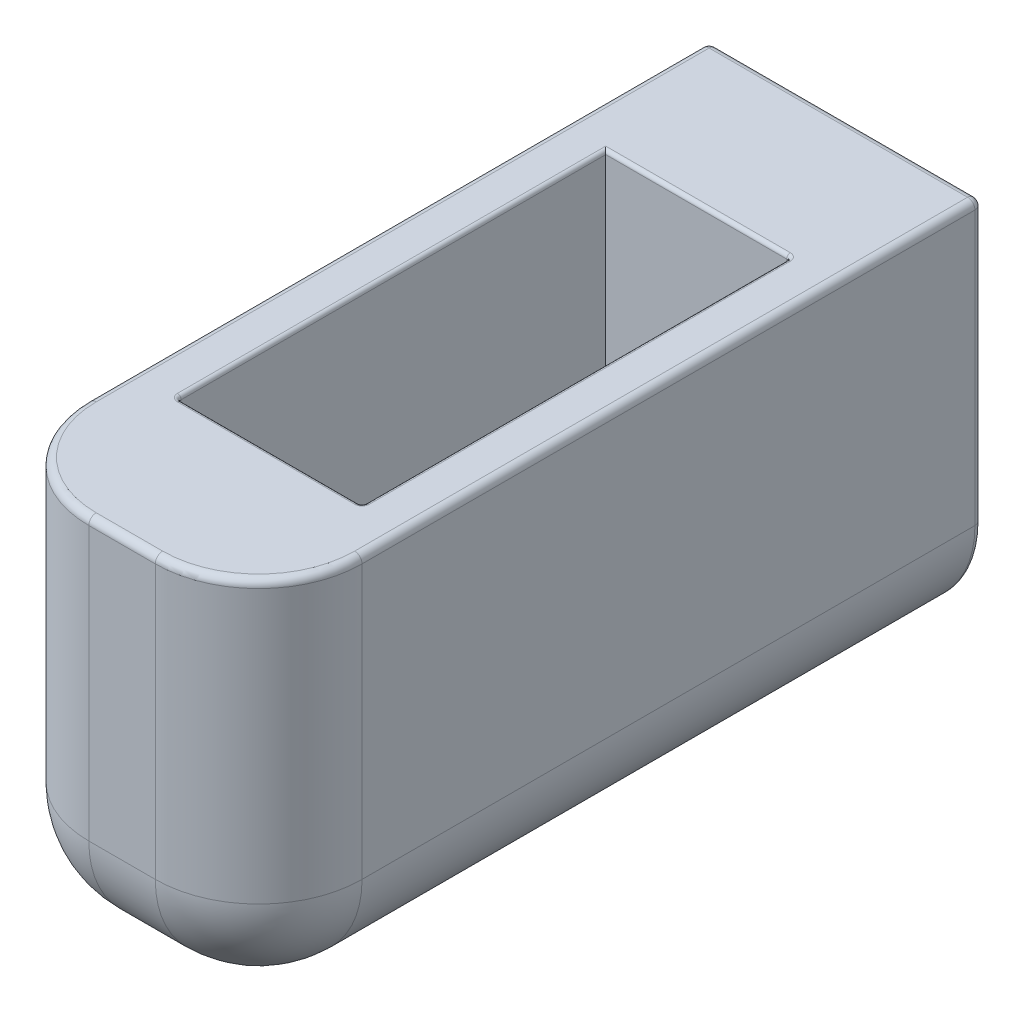
from build123d import *

# Parameters (mm, degrees)
BOSS_EXTRU_1_DEPTH = 29
ESQUISSE2_W        = 18.5
ESQUISSE2_H        = 26
BOSS_EXTRU_2_DEPTH = 10
ESQUISSE3_W        = 18.5
ESQUISSE3_H        = 26
BOSS_EXTRU_3_DEPTH = 10
CONG_3_R           = 7
CONG_4_R           = 7
CONG_5_R           = 7
CONG_6_R           = 0.5
CONG_7_R           = 0.5
CONG_8_R           = 0.25


with BuildPart() as part:
    # Esquisse1 → Boss.-Extru.1 (new body)
    with BuildSketch(Plane.XY):
        Polygon((0, 0), (3, 0), (3, -23), (15.5, -23), (15.5, 0), (18.5, 0), (18.5, -26), (0, -26), align=None)
    extrude(amount=BOSS_EXTRU_1_DEPTH)

    # Esquisse2 → Boss.-Extru.2 (add)
    with BuildSketch(Plane(origin=(0, 0, 0), x_dir=(-1, 0, 0), z_dir=(0, 0, -1))):
        with Locations((-9.25, -13)):
            Rectangle(ESQUISSE2_W, ESQUISSE2_H)
    extrude(amount=BOSS_EXTRU_2_DEPTH)

    # Esquisse3 → Boss.-Extru.3 (add)
    with BuildSketch(Plane.XY.offset(29)):
        with Locations((9.25, -13)):
            Rectangle(ESQUISSE3_W, ESQUISSE3_H)
    extrude(amount=BOSS_EXTRU_3_DEPTH)

    # Congé3
    cong_3_edges = [part.edges().sort_by_distance(p)[0] for p in [
        (9.25, -26, 39),
    ]]
    fillet(cong_3_edges, radius=CONG_3_R)

    # Congé4
    cong_4_edges = [part.edges().sort_by_distance(p)[0] for p in [
        (18.5, -9.5, 39),
        (18.5, -26, 11),
        (18.5, -23.949747468, 36.949747468),
    ]]
    fillet(cong_4_edges, radius=CONG_4_R)

    # Congé5
    cong_5_edges = [part.edges().sort_by_distance(p)[0] for p in [
        (0, -9.5, 39),
        (0, -26, 11),
        (0, -23.949747468, 36.949747468),
    ]]
    fillet(cong_5_edges, radius=CONG_5_R)

    # Congé6
    cong_6_edges = [part.edges().sort_by_distance(p)[0] for p in [
        (18.5, -9.5, -10),
        (9.25, -26, -10),
        (16.449747468, -23.949747468, -10),
        (0, -9.5, -10),
        (2.050252532, -23.949747468, -10),
    ]]
    fillet(cong_6_edges, radius=CONG_6_R)

    # Congé7
    cong_7_edges = [part.edges().sort_by_distance(p)[0] for p in [
        (9.25, 0, 39),
        (18.5, 0, 11.25),
        (16.449747468, 0, 36.949747468),
        (0, 0, 11.25),
        (2.050252532, 0, 36.949747468),
        (9.25, 0, -10),
        (0.146446609, 0, -9.853553391),
        (18.353553391, 0, -9.853553391),
    ]]
    fillet(cong_7_edges, radius=CONG_7_R)

    # Congé8
    cong_8_edges = [part.edges().sort_by_distance(p)[0] for p in [
        (3, 0, 14.5),
        (3, -23, 14.5),
        (15.5, -23, 14.5),
        (15.5, 0, 14.5),
        (15.5, -11.5, 29),
        (9.25, -23, 29),
        (3, -11.5, 29),
        (9.25, 0, 0),
        (9.25, 0, 29),
        (9.25, -23, 0),
        (15.5, -11.5, 0),
    ]]
    fillet(cong_8_edges, radius=CONG_8_R)


solid = part.part
